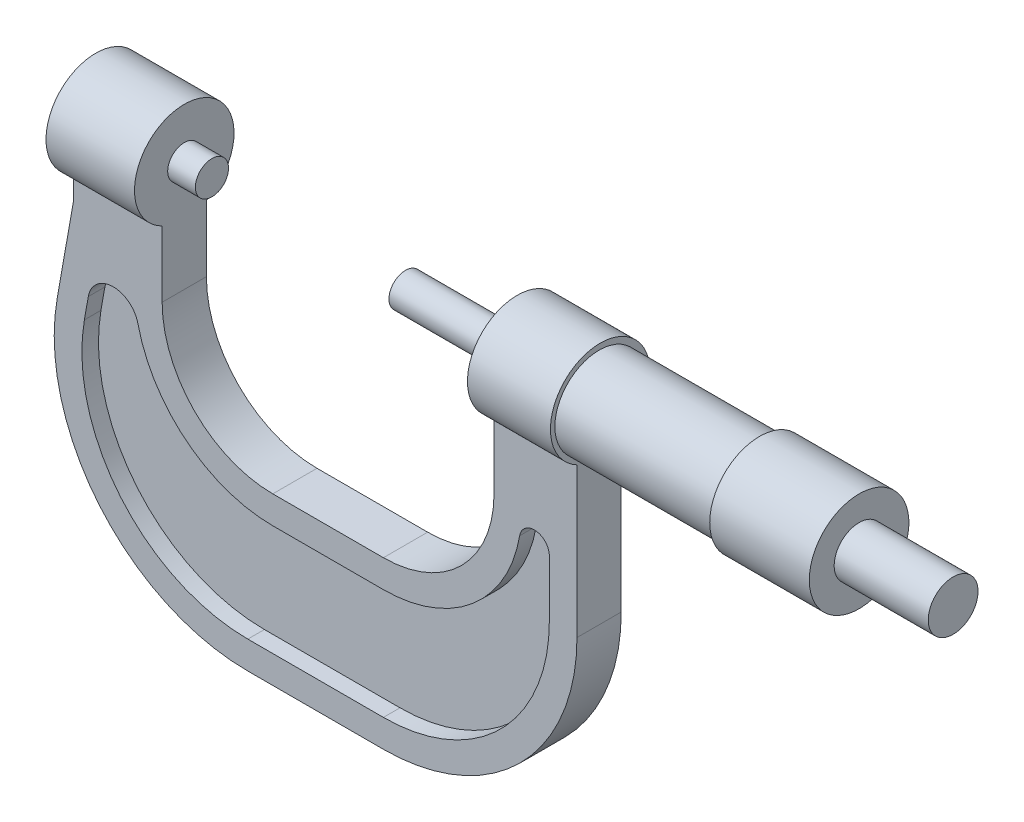
from build123d import *

# Parameters (mm, degrees)
SKETCH2_R           = 4.5
BOSS_EXTRUDE1_DEPTH = 17
SKETCH3_R           = 9
BOSS_EXTRUDE2_DEPTH = 18
SKETCH4_R           = 8
BOSS_EXTRUDE3_DEPTH = 29
SKETCH5_R           = 9
BOSS_EXTRUDE4_DEPTH = 15
SKETCH6_R           = 3
BOSS_EXTRUDE5_DEPTH = 20
BOSS_EXTRUDE6_DEPTH = 4
SKETCH17_R          = 3
BOSS_EXTRUDE7_DEPTH = 5
SKETCH18_R          = 9
BOSS_EXTRUDE8_DEPTH = 16
CUT_EXTRUDE1_DEPTH  = 3


with BuildPart() as part:
    # Sketch2 → Boss-Extrude1 (new body)
    with BuildSketch(Plane.YZ):
        Circle(SKETCH2_R)
    extrude(amount=BOSS_EXTRUDE1_DEPTH)

    # Sketch3 → Boss-Extrude2 (add)
    with BuildSketch(Plane(origin=(0, 0, 0), x_dir=(0, -1, 0), z_dir=(-1, 0, 0))):
        Circle(SKETCH3_R)
    extrude(amount=BOSS_EXTRUDE2_DEPTH)

    # Sketch4 → Boss-Extrude3 (add)
    with BuildSketch(Plane(origin=(-18, 0, 0), x_dir=(0, -1, 0), z_dir=(-1, 0, 0))):
        Circle(SKETCH4_R)
    extrude(amount=BOSS_EXTRUDE3_DEPTH)

    # Sketch5 → Boss-Extrude4 (add)
    with BuildSketch(Plane(origin=(-47, 0, 0), x_dir=(0, -1, 0), z_dir=(-1, 0, 0))):
        with Locations((0, -0.197923741)):
            Circle(SKETCH5_R)
    extrude(amount=BOSS_EXTRUDE4_DEPTH)

    # Sketch6 → Boss-Extrude5 (add)
    with BuildSketch(Plane(origin=(-62, 0, 0), x_dir=(0, -1, 0), z_dir=(-1, 0, 0))):
        Circle(SKETCH6_R)
    extrude(amount=BOSS_EXTRUDE5_DEPTH)

    # Sketch16 → Boss-Extrude6 (add, symmetric)
    with BuildSketch(Plane(origin=(0, 0, 0), x_dir=(0, 1, 0), z_dir=(0, 0, 1))):
        with BuildLine():
            Line((0, 62), (-20, 62))
            ThreePointArc((-20, 62), (-34.142135624, 67.857864376), (-40, 82))
            Line((-40, 82), (-40, 102))
            ThreePointArc((-40, 102), (-34.142135624, 116.142135624), (-20, 122))
            Line((-20, 122), (0, 122))
            Line((0, 122), (0, 138))
            Line((0, 138), (-12, 138))
            Line((-12, 138), (-28.922313782, 140.983860496))
            ThreePointArc((-28.922313782, 140.983860496), (-57.497566339, 133.327144649), (-70, 106.51558914))
            Line((-70, 106.51558914), (-70, 82))
            ThreePointArc((-70, 82), (-59.748737342, 57.251262658), (-35, 47))
            Line((-35, 47), (0, 47))
            Line((0, 47), (0, 62))
        make_face()
    extrude(amount=BOSS_EXTRUDE6_DEPTH, both=True)



with BuildPart() as body_2:
    # Sketch17 → Boss-Extrude7 (new body)
    with BuildSketch(Plane.ZY.offset(117)):
        Circle(SKETCH17_R)
    extrude(amount=BOSS_EXTRUDE7_DEPTH)


with BuildPart() as part_1:
    add(part.part)

    add(body_2.part)  # Boss-Extrude8 merges body 2
    # Sketch18 → Boss-Extrude8 (add)
    with BuildSketch(Plane(origin=(-122, 0, 0), x_dir=(0, -1, 0), z_dir=(-1, 0, 0))):
        Circle(SKETCH18_R)
    extrude(amount=BOSS_EXTRUDE8_DEPTH)

    # Sketch21 → Cut-Extrude1 (cut)
    with BuildSketch(Plane.XY.offset(4)):
        with BuildLine():
            Line((-106.51558914, -65), (-82, -65))
            ThreePointArc((-82, -65), (-60.786796564, -56.213203436), (-52, -35))
            Line((-52, -35), (-52, -24.70089464))
            ThreePointArc((-52, -24.70089464), (-54.470885592, -22.009811643), (-57.362613993, -24.24254767))
            ThreePointArc((-57.362613993, -24.24254767), (-65.891984786, -39.11888715), (-82, -45))
            Line((-82, -45), (-102, -45))
            ThreePointArc((-102, -45), (-117.587304364, -39.545739757), (-126.373231569, -25.562875413))
            ThreePointArc((-126.373231569, -25.562875413), (-130.955140822, -22.001423997), (-135.353853676, -25.786810875))
            Line((-135.353853676, -25.786810875), (-136.059821731, -29.79055467))
            ThreePointArc((-136.059821731, -29.79055467), (-129.496922434, -54.283628291), (-106.51558914, -65))
        make_face()
    cut_extrude1 = extrude(amount=-CUT_EXTRUDE1_DEPTH, mode=Mode.SUBTRACT)

    # Mirror1: Cut-Extrude1 across plane
    add(cut_extrude1.mirror(Plane.XY), mode=Mode.SUBTRACT)


solid = part_1.part
